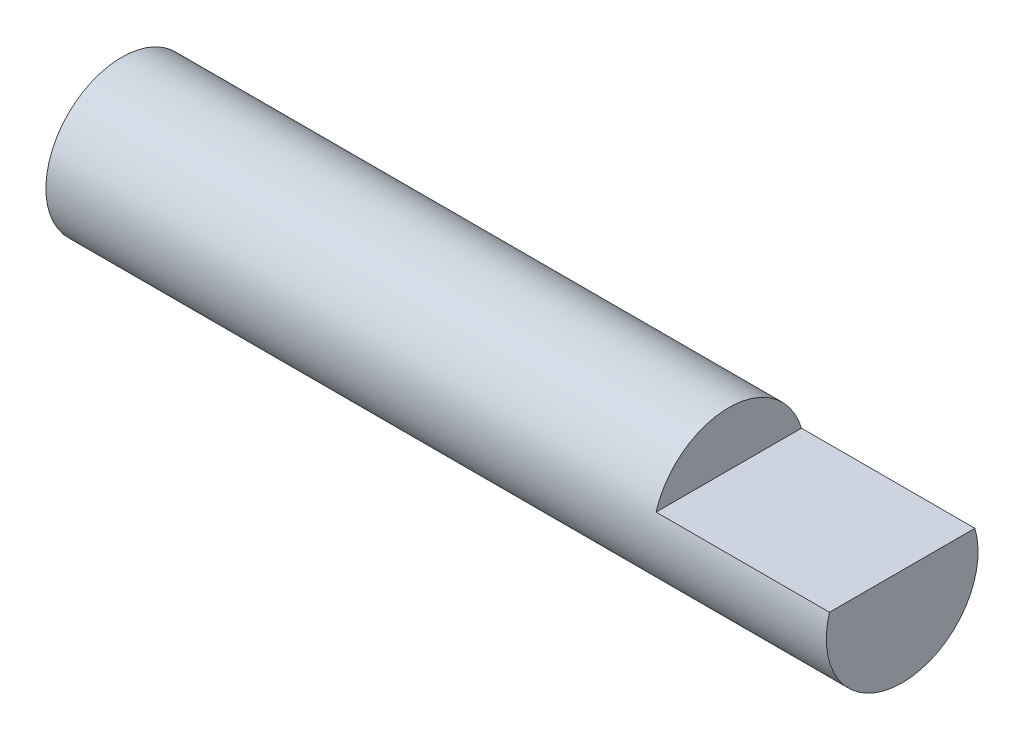
from build123d import *

# Parameters (mm, degrees)
SKETCH1_R          = 5.55625
BASE_EXTRUDE_DEPTH = 57.15
CUT_EXTRUDE1_DEPTH = 12.7


with BuildPart() as part:
    # Sketch1 → Base-Extrude (new body)
    with BuildSketch(Plane(origin=(0, 0, 0), x_dir=(0, 0, -1), z_dir=(1, 0, 0))):
        Circle(SKETCH1_R)
    extrude(amount=BASE_EXTRUDE_DEPTH)

    # Sketch2 → Cut-Extrude1 (cut)
    with BuildSketch(Plane(origin=(57.15, 0, 0), x_dir=(0, 0, -1), z_dir=(1, 0, 0))):
        with BuildLine():
            Line((-5.324636871, 1.5875), (5.324636871, 1.5875))
            ThreePointArc((5.324636871, 1.5875), (0, 5.55625), (-5.324636871, 1.5875))
        make_face()
    extrude(amount=-CUT_EXTRUDE1_DEPTH, mode=Mode.SUBTRACT)


solid = part.part
